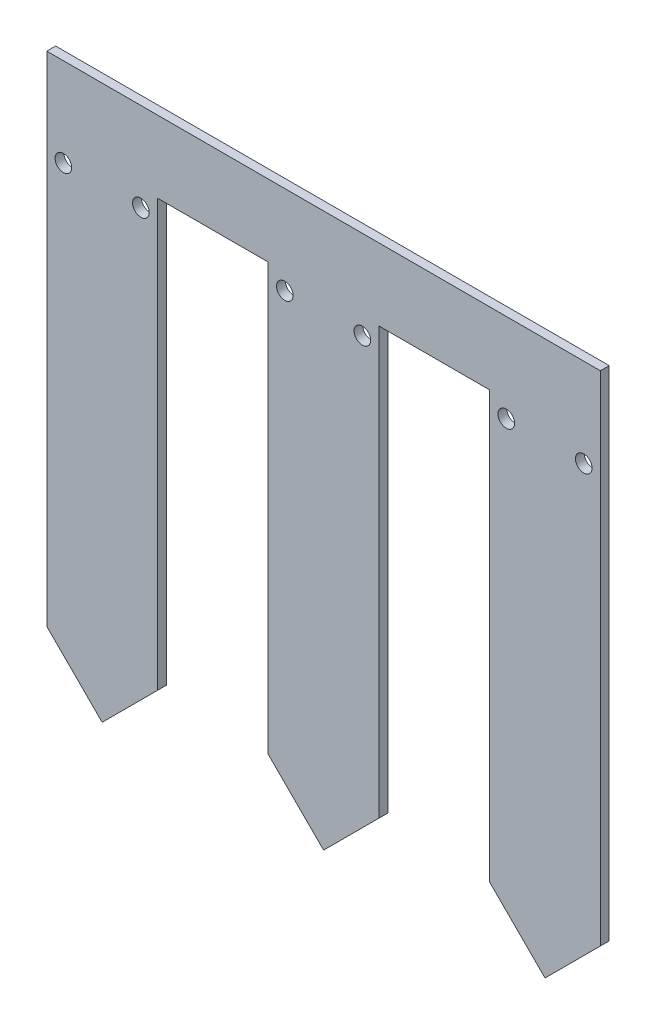
from build123d import *

# Parameters (mm, degrees)
IZIM1_R                     = 1.5
Y_KSEKLIK_EKSTR_ZYON1_DEPTH = 1.6


with BuildPart() as part:
    # Çizim1 → Yükseklik-Ekstrüzyon1 (new body)
    with BuildSketch(Plane.XY):
        Polygon((0, -55), (-10, -45), (-10, 45), (10, 45), (90, 45), (90, -45), (80, -55), (70, -45), (70, 32), (50, 32), (50, -45), (40, -55), (30, -45), (30, 32), (10, 32), (10, -45), align=None)
        with Locations((-7, 29)):
            Circle(IZIM1_R, mode=Mode.SUBTRACT)
        with Locations((7, 29)):
            Circle(IZIM1_R, mode=Mode.SUBTRACT)
        with Locations((33, 29)):
            Circle(IZIM1_R, mode=Mode.SUBTRACT)
        with Locations((47, 29)):
            Circle(IZIM1_R, mode=Mode.SUBTRACT)
        with Locations((73, 29)):
            Circle(IZIM1_R, mode=Mode.SUBTRACT)
        with Locations((87, 29)):
            Circle(IZIM1_R, mode=Mode.SUBTRACT)
    extrude(amount=Y_KSEKLIK_EKSTR_ZYON1_DEPTH)


solid = part.part
